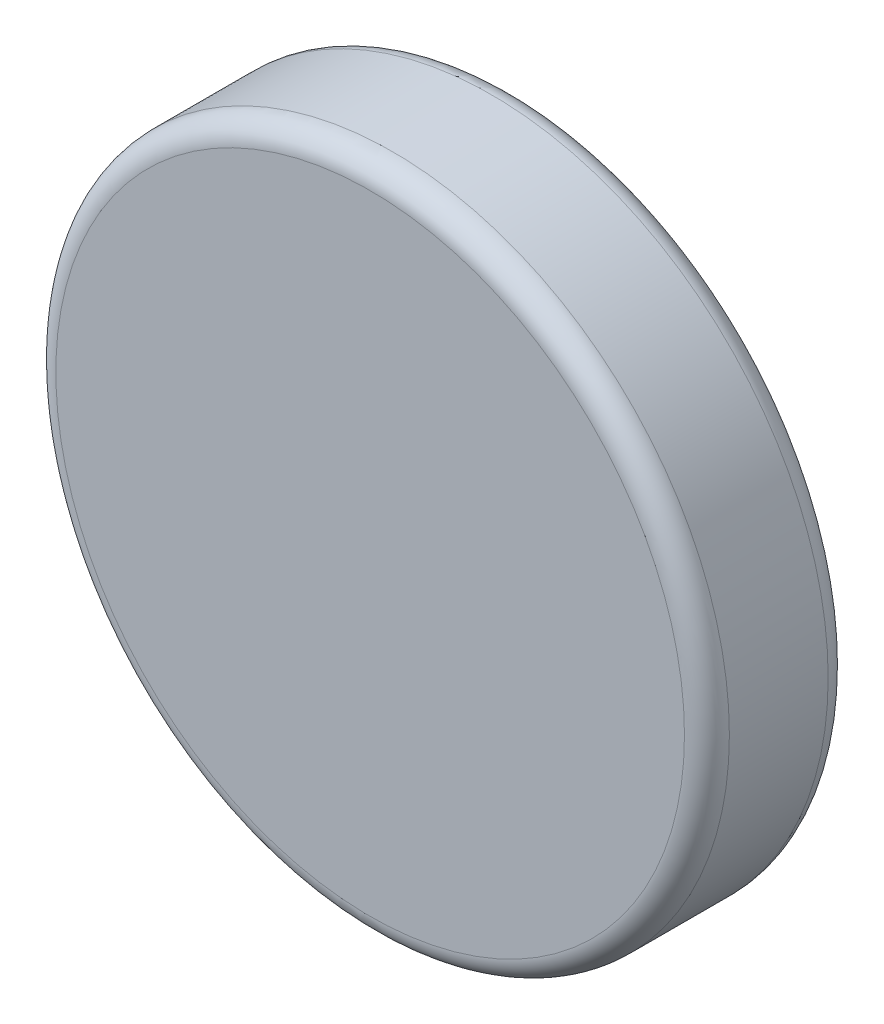
from build123d import *

# Parameters (mm, degrees)
SKETCH1_R           = 7.5
BOSS_EXTRUDE1_DEPTH = 3.2
FILLET1_R           = 0.5


with BuildPart() as part:
    # Sketch1 → Boss-Extrude1 (new body)
    with BuildSketch(Plane.XY):
        Circle(SKETCH1_R)
    extrude(amount=BOSS_EXTRUDE1_DEPTH)

    # Fillet1
    fillet1_edges = [part.edges().sort_by_distance(p)[0] for p in [
        (-7.5, 0, 0),
        (-7.5, 0, 3.2),
    ]]
    fillet(fillet1_edges, radius=FILLET1_R)


solid = part.part
